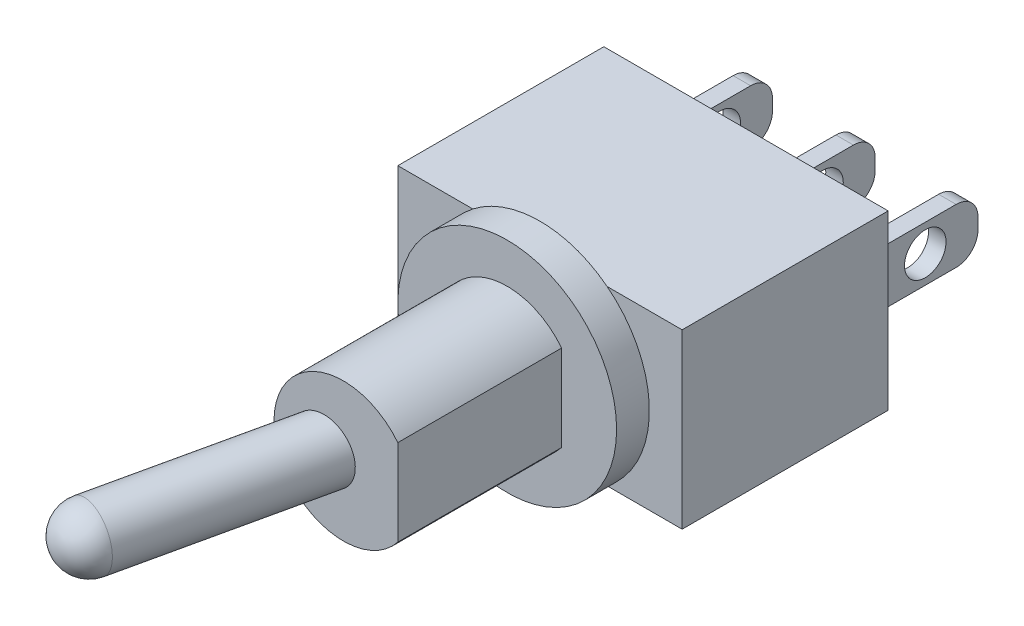
from build123d import *

# Parameters (mm, degrees)
SKETCH2_W           = 13.0048
SKETCH2_H           = 7.8994
BOSS_EXTRUDE1_DEPTH = 9.4234
BOSS_EXTRUDE2_START = 4.7
SKETCH5_R           = 0.95
BOSS_EXTRUDE2_DEPTH = 0.4
LPATTERN1_COUNT     = 3
LPATTERN1_PITCH     = 4.7
SKETCH6_R           = 5.0038
BOSS_EXTRUDE3_DEPTH = 1.4986
BOSS_EXTRUDE5_DEPTH = 7.493


with BuildPart() as part:
    # Sketch2 → Boss-Extrude1 (new body)
    with BuildSketch(Plane.XY):
        Rectangle(SKETCH2_W, SKETCH2_H)
    extrude(amount=-BOSS_EXTRUDE1_DEPTH)

    # Sketch5 → Boss-Extrude2 (add, symmetric)
    with BuildSketch(Plane(origin=(0, 0, 0), x_dir=(0, 0, -1), z_dir=(1, 0, 0)).offset(BOSS_EXTRUDE2_START)):
        with BuildLine():
            ThreePointArc((13.9352, 1.25), (14.642306781, 0.957106781), (14.9352, 0.25))
            Line((14.9352, 0.25), (14.9352, -0.25))
            ThreePointArc((14.9352, -0.25), (14.642306781, -0.957106781), (13.9352, -1.25))
            Line((13.9352, -1.25), (9.4234, -1.25))
            Line((9.4234, -1.25), (9.4234, 1.25))
            Line((9.4234, 1.25), (13.9352, 1.25))
        make_face()
        with Locations((12.5234, 0)):
            Circle(SKETCH5_R, mode=Mode.SUBTRACT)
    boss_extrude2 = extrude(amount=BOSS_EXTRUDE2_DEPTH, both=True)

    # LPattern1: Boss-Extrude2 ×3
    with Locations(*[(-i * LPATTERN1_PITCH, 0, 0) for i in range(1, LPATTERN1_COUNT)]):
        add(boss_extrude2)

    # Sketch6 → Boss-Extrude3 (add)
    with BuildSketch(Plane.XY):
        Circle(SKETCH6_R)
    extrude(amount=BOSS_EXTRUDE3_DEPTH)

    # Sketch7 → Boss-Extrude5 (add)
    with BuildSketch(Plane.XY.offset(1.4986)):
        with BuildLine():
            Line((2.4892, -1.970915615), (2.4892, 1.970915615))
            ThreePointArc((2.4892, 1.970915615), (-3.175, 0), (2.4892, -1.970915615))
        make_face()
    extrude(amount=BOSS_EXTRUDE5_DEPTH)

    # Sketch8 → Revolve1 (revolve)
    with BuildSketch(Plane(origin=(0, 0, 0), x_dir=(1, 0, 0), z_dir=(0, 1, 0))):
        with BuildLine():
            Line((-3.138374402, -19.147892103), (0, -4.9916))
            Line((0, -4.9916), (-1.363885522, -4.689233859))
            Line((-1.363885522, -4.689233859), (-4.199893783, -17.481640441))
            ThreePointArc((-4.199893783, -17.481640441), (-4.014226111, -18.534614134), (-3.138374402, -19.147892103))
        make_face()
    revolve(axis=Axis((-3.138374402, 0, 19.147892103), (0.216439614, 0, -0.976296007)))


solid = part.part
